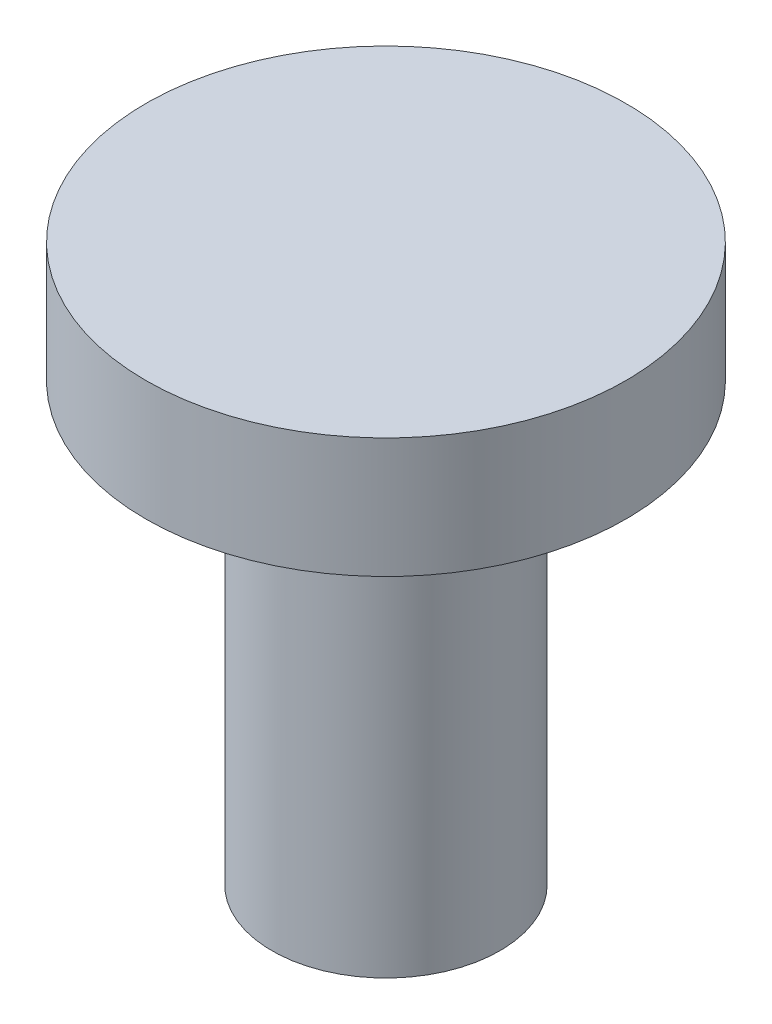
from build123d import *

# Parameters (mm, degrees)
SKETCH1_R           = 4.75
BOSS_EXTRUDE1_DEPTH = 10
SKETCH2_R           = 10
BOSS_EXTRUDE2_DEPTH = 5
SKETCH3_R           = 4.75
BOSS_EXTRUDE3_DEPTH = 13.2
SKETCH4_R           = 4.75
CUT_EXTRUDE1_DEPTH  = 5


with BuildPart() as part:
    # Sketch1 → Boss-Extrude1 (new body)
    with BuildSketch(Plane(origin=(0, 0, 0), x_dir=(1, 0, 0), z_dir=(0, 1, 0))):
        Circle(SKETCH1_R)
    extrude(amount=BOSS_EXTRUDE1_DEPTH)

    # Sketch2 → Boss-Extrude2 (add)
    with BuildSketch(Plane(origin=(0, 10, 0), x_dir=(1, 0, 0), z_dir=(0, 1, 0))):
        Circle(SKETCH2_R)
    extrude(amount=BOSS_EXTRUDE2_DEPTH)

    # Sketch3 → Boss-Extrude3 (add)
    with BuildSketch(Plane.XZ):
        Circle(SKETCH3_R)
    extrude(amount=BOSS_EXTRUDE3_DEPTH)

    # Sketch4 → Cut-Extrude1 (cut)
    with BuildSketch(Plane.XZ.offset(13.2)):
        Circle(SKETCH4_R)
    extrude(amount=-CUT_EXTRUDE1_DEPTH, mode=Mode.SUBTRACT)


solid = part.part
